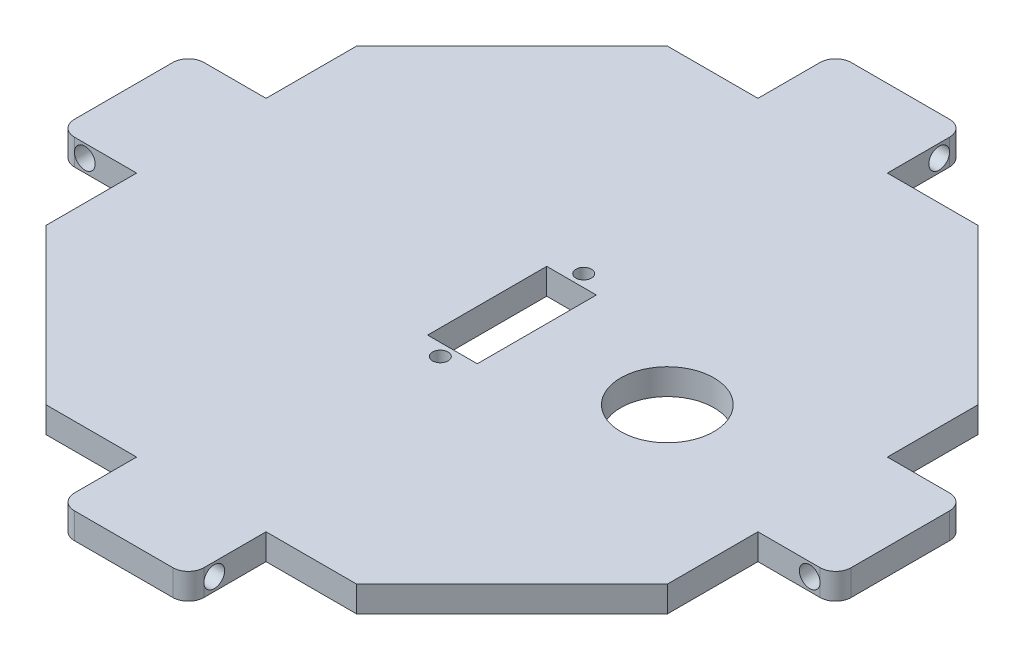
from build123d import *

# Parameters (mm, degrees)
EXTRUDE_1_DEPTH     = 5
FILLET_1_R          = 3
SKETCH_11_R         = 2
CUT_EXTRUDE_6_DEPTH = 88.5
SKETCH_12_R         = 2
CUT_EXTRUDE_7_DEPTH = 88.5
SKETCH_13_R         = 1.5
SKETCH_13_R_2       = 9
SKETCH_13_W         = 9.590692188
SKETCH_13_H         = 23
CUT_EXTRUDE_8_DEPTH = 10


with BuildPart() as part:
    # 스케치1 → 보스-돌출1 (new body)
    with BuildSketch(Plane(origin=(0, 0, 0), x_dir=(1, 0, 0), z_dir=(0, 1, 0))):
        Polygon((-60, -30), (-30, -60), (-12.5, -60), (-12.5, -75), (12.5, -75), (12.5, -60), (30, -60), (60, -30), (60, -12.5), (75, -12.5), (75, 12.5), (60, 12.5), (60, 30), (30, 60), (12.5, 60), (12.5, 75), (-12.5, 75), (-12.5, 60), (-30, 60), (-60, 30), (-60, 12.5), (-75, 12.5), (-75, -12.5), (-60, -12.5), align=None)
    extrude(amount=EXTRUDE_1_DEPTH)

    # 필렛1
    fillet_1_edges = [part.edges().sort_by_distance(p)[0] for p in [
        (-12.5, 2.5, -75),
        (12.5, 2.5, -75),
        (75, 2.5, -12.5),
        (75, 2.5, 12.5),
        (12.5, 2.5, 75),
        (-12.5, 2.5, 75),
        (-75, 2.5, 12.5),
        (-75, 2.5, -12.5),
    ]]
    fillet(fillet_1_edges, radius=FILLET_1_R)

    # 스케치11 → 컷-돌출6 (cut, through all)
    with BuildSketch(Plane.XY.offset(12.5)):
        with Locations((-70, 2.5)):
            Circle(SKETCH_11_R)
        with Locations((70, 2.5)):
            Circle(SKETCH_11_R)
    extrude(amount=-CUT_EXTRUDE_6_DEPTH, mode=Mode.SUBTRACT)

    # 스케치12 → 컷-돌출7 (cut, through all)
    with BuildSketch(Plane.ZY.offset(12.5)):
        with Locations((-70, 2.5)):
            Circle(SKETCH_12_R)
        with Locations((70, 2.5)):
            Circle(SKETCH_12_R)
    extrude(amount=-CUT_EXTRUDE_7_DEPTH, mode=Mode.SUBTRACT)

    # 스케치13 → 컷-돌출8 (cut)
    with BuildSketch(Plane(origin=(0, 5, 0), x_dir=(1, 0, 0), z_dir=(0, 1, 0))):
        with Locations((0, 13.85)):
            Circle(SKETCH_13_R)
        with Locations((30, 0)):
            Circle(SKETCH_13_R_2)
        with Locations((0, -13.85)):
            Circle(SKETCH_13_R)
        Rectangle(SKETCH_13_W, SKETCH_13_H)
    extrude(amount=-CUT_EXTRUDE_8_DEPTH, mode=Mode.SUBTRACT)


solid = part.part
